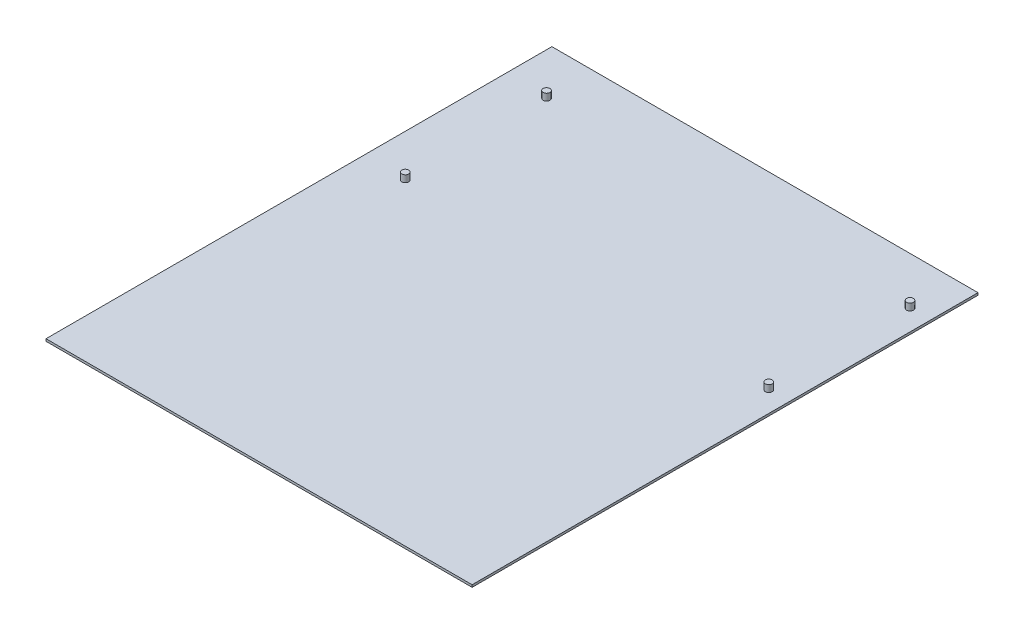
from build123d import *

# Parameters (mm, degrees)
SKETCH1_W           = 187
SKETCH1_H           = 222
BOSS_EXTRUDE1_DEPTH = 1
SKETCH2_R           = 1.5
BOSS_EXTRUDE2_DEPTH = 3


with BuildPart() as part:
    # Sketch1 → Boss-Extrude1 (new body)
    with BuildSketch(Plane(origin=(0, 0, 0), x_dir=(1, 0, 0), z_dir=(0, 1, 0))):
        with Locations((37.397058758, 75.462578399)):
            Rectangle(SKETCH1_W, SKETCH1_H)
    extrude(amount=BOSS_EXTRUDE1_DEPTH)

    # Sketch2 → Boss-Extrude2 (add)
    with BuildSketch(Plane(origin=(0, 1, 0), x_dir=(1, 0, 0), z_dir=(0, 1, 0))):
        with Locations((121.897058758, 165.632578399)):
            Circle(SKETCH2_R)
        with Locations((-37.614941242, 165.632578399)):
            Circle(SKETCH2_R)
        with Locations((121.897058758, 103.656578399)):
            Circle(SKETCH2_R)
        with Locations((-37.614941242, 103.652578399)):
            Circle(SKETCH2_R)
    extrude(amount=BOSS_EXTRUDE2_DEPTH)


solid = part.part
